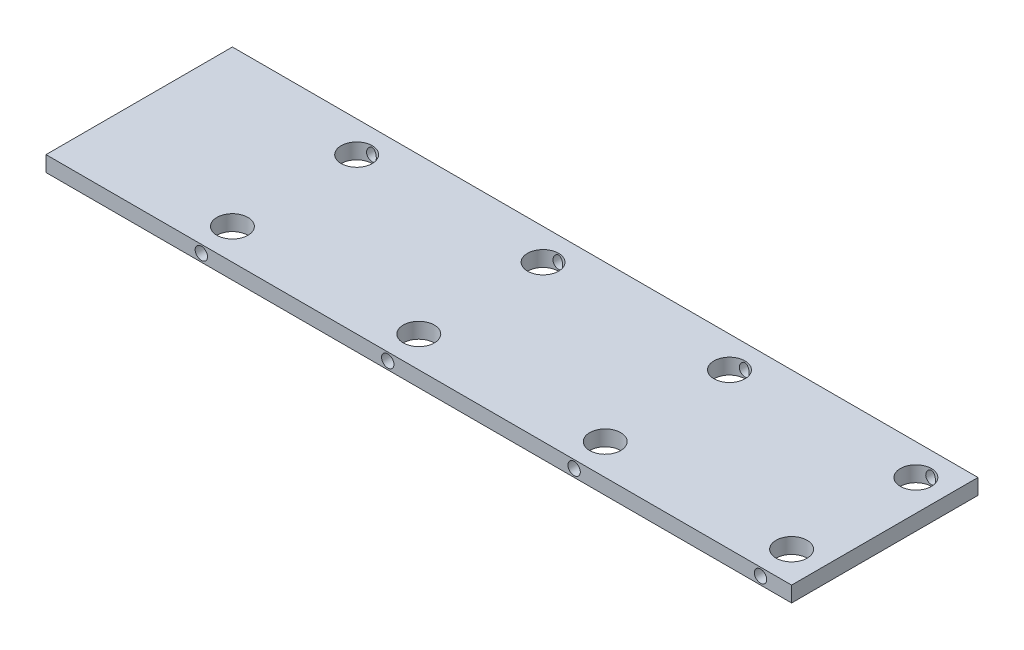
from build123d import *

# Parameters (mm, degrees)
SKETCH1_W            = 304.8
SKETCH1_H            = 6.35
BOSS_EXTRUDE1_DEPTH  = 76.2
LPATTERN1_COUNT      = 4
LPATTERN1_PITCH      = 76.2
SKETCH4_R            = 6.35
CUT_EXTRUDE1_DEPTH   = 7.35
LPATTERN2_COUNT      = 4
LPATTERN2_PITCH      = 76.2
LPATTERN2_COUNT_DIR2 = 2
LPATTERN2_PITCH_DIR2 = 50.8


with BuildPart() as part:
    # Sketch1 → Boss-Extrude1 (new body)
    with BuildSketch(Plane.XY):
        with Locations((79.16160748, 30.070069775)):
            Rectangle(SKETCH1_W, SKETCH1_H)
    extrude(amount=BOSS_EXTRUDE1_DEPTH)

    # Sketch2 → #8 (0.199) Diameter Hole1 (revolve, cut)
    with BuildSketch(Plane(origin=(218.86160748, 30.070069775, 76.2), x_dir=(0, -1, 0), z_dir=(1, 0, 0))):
        Polygon((0, 0), (0, 7.868555042), (2.5273, 6.35), (2.5273, 0), align=None)
    f_8_0_199_diameter_hole1 = revolve(axis=Axis((218.86160748, 30.070069775, 82.55), (0, 0, -1)), mode=Mode.SUBTRACT)

    # LPattern1: #8 (0.199) Diameter Hole1 ×4
    with Locations(*[(-i * LPATTERN1_PITCH, 0, 0) for i in range(1, LPATTERN1_COUNT)]):
        add(f_8_0_199_diameter_hole1, mode=Mode.SUBTRACT)

    # Sketch4 → Cut-Extrude1 (cut, through all)
    with BuildSketch(Plane(origin=(0, 33.245069775, 0), x_dir=(1, 0, 0), z_dir=(0, 1, 0))):
        with Locations(Location((218.86160748, -63.5, 0), (0, 0, 270))):  # turned: the seam where the file's is
            Circle(SKETCH4_R)
    cut_extrude1 = extrude(amount=-CUT_EXTRUDE1_DEPTH, mode=Mode.SUBTRACT)

    # LPattern2: Cut-Extrude1 4 × 2
    with Locations(*[(-i * LPATTERN2_PITCH, 0, -j * LPATTERN2_PITCH_DIR2) for i in range(LPATTERN2_COUNT) for j in range(LPATTERN2_COUNT_DIR2) if (i, j) != (0, 0)]):
        add(cut_extrude1, mode=Mode.SUBTRACT)

    # Mirror1: #8 (0.199) Diameter Hole1 across plane
    add(f_8_0_199_diameter_hole1.mirror(Plane.XY.offset(38.1)), mode=Mode.SUBTRACT)

    # LPattern3 copy 1 sketch → LPattern3 copy 1 (revolve, cut)
    with BuildSketch(Plane(origin=(142.66160748, 30.070069775, 0), x_dir=(0, -1, 0), z_dir=(1, 0, 0))):
        Polygon((0, 0), (0, -7.868555042), (2.5273, -6.35), (2.5273, 0), align=None)
    revolve(axis=Axis((142.66160748, 30.070069775, -6.35), (0, 0, -1)), mode=Mode.SUBTRACT)

    # LPattern3 copy 2 sketch → LPattern3 copy 2 (revolve, cut)
    with BuildSketch(Plane(origin=(66.46160748, 30.070069775, 0), x_dir=(0, -1, 0), z_dir=(1, 0, 0))):
        Polygon((0, 0), (0, -7.868555042), (2.5273, -6.35), (2.5273, 0), align=None)
    revolve(axis=Axis((66.46160748, 30.070069775, -6.35), (0, 0, -1)), mode=Mode.SUBTRACT)

    # LPattern3 copy 3 sketch → LPattern3 copy 3 (revolve, cut)
    with BuildSketch(Plane(origin=(-9.73839252, 30.070069775, 0), x_dir=(0, -1, 0), z_dir=(1, 0, 0))):
        Polygon((0, 0), (0, -7.868555042), (2.5273, -6.35), (2.5273, 0), align=None)
    revolve(axis=Axis((-9.73839252, 30.070069775, -6.35), (0, 0, -1)), mode=Mode.SUBTRACT)

    # LPattern3 copy 4 sketch → LPattern3 copy 4 (revolve, cut)
    with BuildSketch(Plane(origin=(142.66160748, 30.070069775, 76.2), x_dir=(0, -1, 0), z_dir=(1, 0, 0))):
        Polygon((0, 0), (0, 7.868555042), (2.5273, 6.35), (2.5273, 0), align=None)
    revolve(axis=Axis((142.66160748, 30.070069775, 82.55), (0, 0, -1)), mode=Mode.SUBTRACT)

    # LPattern3 copy 5 sketch → LPattern3 copy 5 (revolve, cut)
    with BuildSketch(Plane(origin=(66.46160748, 30.070069775, 76.2), x_dir=(0, -1, 0), z_dir=(1, 0, 0))):
        Polygon((0, 0), (0, 7.868555042), (2.5273, 6.35), (2.5273, 0), align=None)
    revolve(axis=Axis((66.46160748, 30.070069775, 82.55), (0, 0, -1)), mode=Mode.SUBTRACT)

    # LPattern3 copy 6 sketch → LPattern3 copy 6 (revolve, cut)
    with BuildSketch(Plane(origin=(-9.73839252, 30.070069775, 76.2), x_dir=(0, -1, 0), z_dir=(1, 0, 0))):
        Polygon((0, 0), (0, 7.868555042), (2.5273, 6.35), (2.5273, 0), align=None)
    revolve(axis=Axis((-9.73839252, 30.070069775, 82.55), (0, 0, -1)), mode=Mode.SUBTRACT)


solid = part.part
